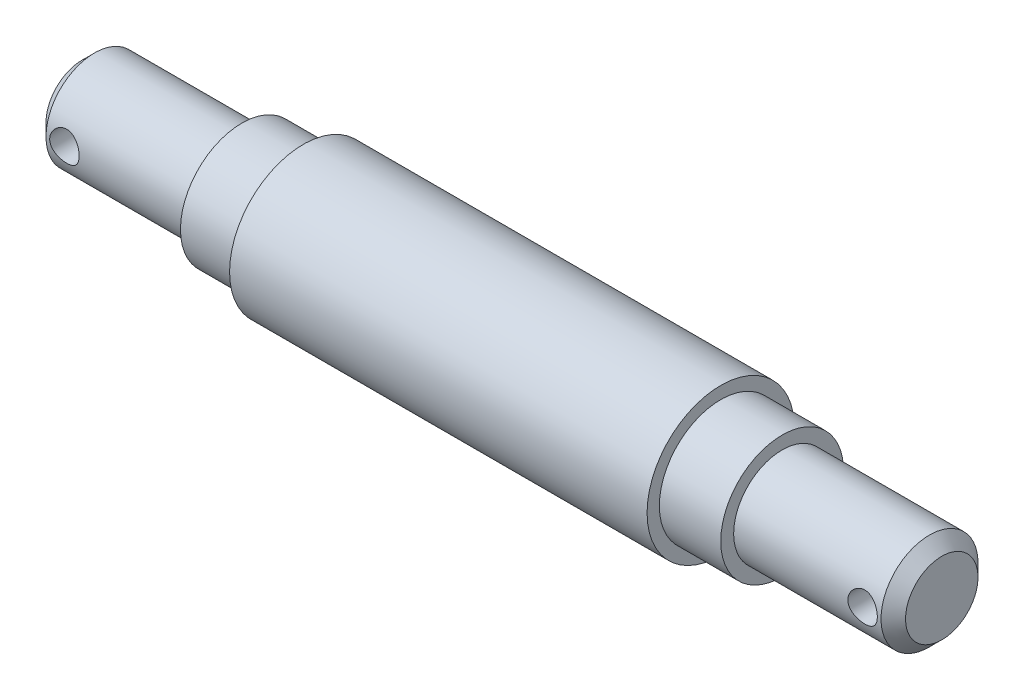
from build123d import *

# Parameters (mm, degrees)
SZKIC2_R                        = 1.2
WYTNIJ_WYCI_GNI_CIE1_DEPTH      = 7
WYTNIJ_WYCI_GNI_CIE1_DEPTH_BACK = 7


with BuildPart() as part:
    # Szkic1 → Obrót1 (revolve)
    with BuildSketch(Plane.XY):
        Polygon((0, 0), (70, 0), (70, 2.95), (69, 3.95), (57, 3.95), (57, 5), (52, 5), (52, 6), (18, 6), (18, 5), (13, 5), (13, 3.95), (1, 3.95), (0, 2.95), align=None)
    revolve(axis=Axis((0, 0, 0), (1, 0, 0)))

    # Szkic2 → Wytnij-wyciągnięcie1 (cut, two sides)
    with BuildSketch(Plane.XY) as wytnij_wyci_gni_cie1_sk:
        with Locations((67.5, 0)):
            Circle(SZKIC2_R)
        with Locations((2.5, 0)):
            Circle(SZKIC2_R)
    extrude(amount=WYTNIJ_WYCI_GNI_CIE1_DEPTH, mode=Mode.SUBTRACT)
    extrude(wytnij_wyci_gni_cie1_sk.sketch, amount=-WYTNIJ_WYCI_GNI_CIE1_DEPTH_BACK, mode=Mode.SUBTRACT)


solid = part.part
